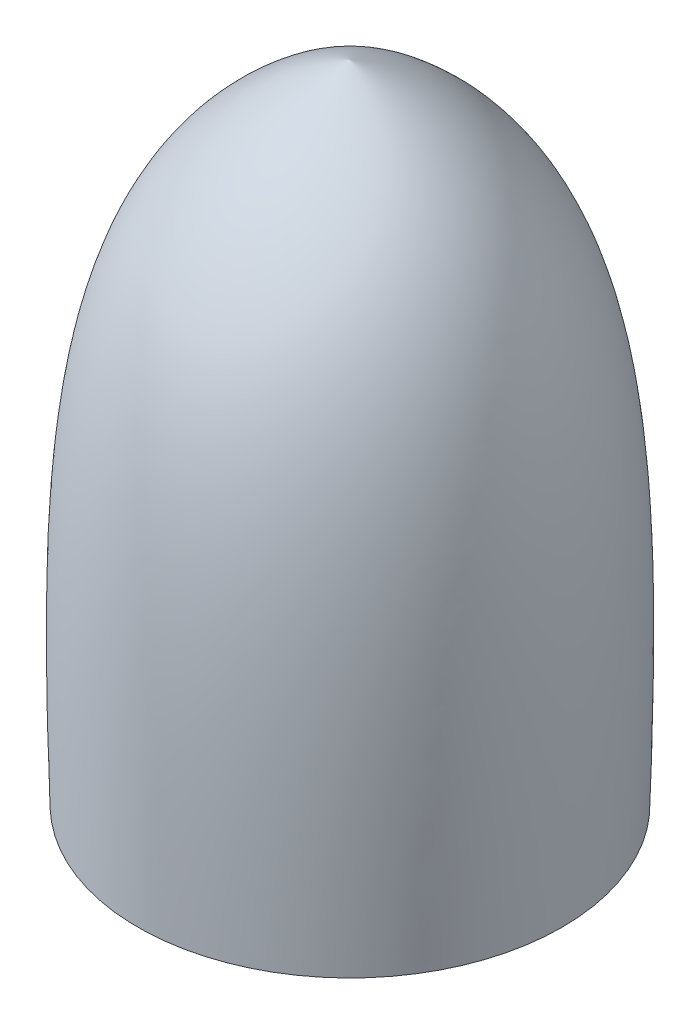
from build123d import *


with BuildPart() as part:
    # Sketch1 → Revolve1 (revolve)
    with BuildSketch(Plane.XY):
        with BuildLine():
            Line((0, 3.695991235), (0, 2.695991235))
            Line((0, 2.695991235), (1.2, 2.695991235))
            Line((1.2, 2.695991235), (1.2, -3.304008765))
            Line((1.2, -3.304008765), (2.301298402, -3.304008765))
            add(Edge.make_bspline(
                [(0, 3.695991235), (2.318415108, 2.758230162), (2.410460271, 0.516656665), (2.301298402, -3.304008765)],
                knots=[0, 0, 0, 0, 1, 1, 1, 1], degree=3))
        make_face()
    revolve(axis=Axis((0, 3.695991235, 0), (0, -1, 0)))


solid = part.part
